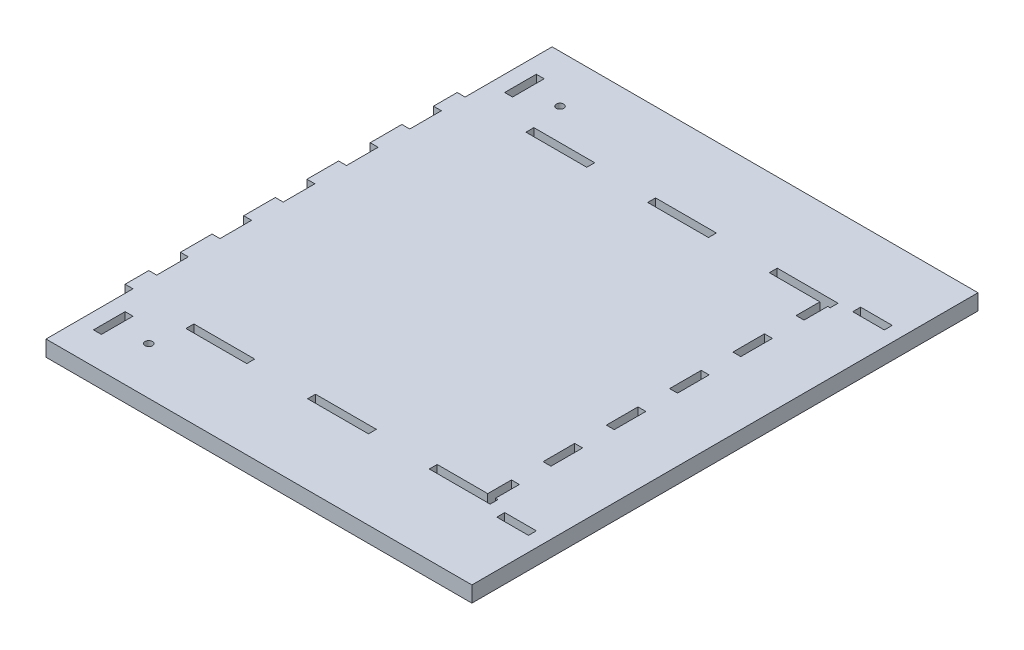
from build123d import *

# Parameters (mm, degrees)
SKETCH1_W           = 24.429357143
SKETCH1_H           = 3.175
SKETCH1_W_2         = 24.429357142
SKETCH1_W_3         = 3.175
SKETCH1_H_2         = 12.7
BOSS_EXTRUDE1_DEPTH = 6.35
SKETCH2_R           = 1.499997
SKETCH2_R_2         = 1.5
SKETCH2_W           = 12.7
SKETCH2_H           = 3.175
SKETCH2_W_2         = 3.175
SKETCH2_H_2         = 12.7
CUT_EXTRUDE1_DEPTH  = 7.35
SKETCH3_W           = 171.0055
SKETCH3_H           = 101.6
SKETCH3_H_2         = 44.45
CUT_EXTRUDE2_DEPTH  = 7.35


with BuildPart() as part:
    # Sketch1 → Boss-Extrude1 (new body)
    with BuildSketch(Plane(origin=(0, 0, 0), x_dir=(1, 0, 0), z_dir=(0, 1, 0))):
        Polygon((0, 174.625), (0, 95.25), (-3.175, 95.25), (-3.175, 85.725), (0, 85.725), (0, 73.025), (-3.175, 73.025), (-3.175, 60.325), (0, 60.325), (0, 47.625), (-3.175, 47.625), (-3.175, 34.925), (0, 34.925), (0, 22.225), (-3.175, 22.225), (-3.175, 9.525), (0, 9.525), (0, -3.175), (-3.175, -3.175), (-3.175, -15.875), (0, -15.875), (0, -28.575), (-3.175, -28.575), (-3.175, -38.1), (0, -38.1), (0, -174.625), (171.0055, -174.625), (171.0055, 174.625), align=None)
        with Locations((36.644035714, -39.6875)):
            Rectangle(SKETCH1_W, SKETCH1_H, mode=Mode.SUBTRACT)
        with Locations((85.50275, -39.6875)):
            Rectangle(SKETCH1_W_2, SKETCH1_H, mode=Mode.SUBTRACT)
        Polygon((122.146785714, -38.1), (142.4305, -38.1), (142.4305, -28.575), (145.6055, -28.575), (145.6055, -38.1), (146.576142857, -38.1), (146.576142857, -41.275), (122.146785714, -41.275), align=None, mode=Mode.SUBTRACT)
        with Locations((144.018, -9.525)):
            Rectangle(SKETCH1_W_3, SKETCH1_H_2, mode=Mode.SUBTRACT)
        with Locations((144.018, 15.875)):
            Rectangle(SKETCH1_W_3, SKETCH1_H_2, mode=Mode.SUBTRACT)
        with Locations((144.018, 41.275)):
            Rectangle(SKETCH1_W_3, SKETCH1_H_2, mode=Mode.SUBTRACT)
        with Locations((144.018, 66.675)):
            Rectangle(SKETCH1_W_3, SKETCH1_H_2, mode=Mode.SUBTRACT)
        Polygon((142.4305, 85.725), (142.4305, 95.25), (122.146785714, 95.25), (122.146785714, 98.425), (146.576142857, 98.425), (146.576142857, 95.25), (145.6055, 95.25), (145.6055, 85.725), align=None, mode=Mode.SUBTRACT)
        with Locations((85.50275, 96.8375)):
            Rectangle(SKETCH1_W_2, SKETCH1_H, mode=Mode.SUBTRACT)
        with Locations((36.644035714, 96.8375)):
            Rectangle(SKETCH1_W, SKETCH1_H, mode=Mode.SUBTRACT)
    extrude(amount=BOSS_EXTRUDE1_DEPTH)

    # Sketch2 → Cut-Extrude1 (cut, through all)
    with BuildSketch(Plane(origin=(0, 6.35, 0), x_dir=(1, 0, 0), z_dir=(0, 1, 0))):
        with Locations((9.525, -165.1)):
            Circle(SKETCH2_R)
        with Locations((9.525, 165.1)):
            Circle(SKETCH2_R)
        with Locations((22.225, -53.975)):
            Circle(SKETCH2_R_2)
        with Locations((22.225, 111.125)):
            Circle(SKETCH2_R_2)
        with Locations((158.790821429, -42.8625)):
            Rectangle(SKETCH2_W, SKETCH2_H)
        with Locations((158.790821429, 100.0125)):
            Rectangle(SKETCH2_W, SKETCH2_H)
        with Locations((7.9375, -53.975)):
            Rectangle(SKETCH2_W_2, SKETCH2_H_2)
        with Locations((7.9375, 111.125)):
            Rectangle(SKETCH2_W_2, SKETCH2_H_2)
    extrude(amount=-CUT_EXTRUDE1_DEPTH, mode=Mode.SUBTRACT)

    # Sketch3 → Cut-Extrude2 (cut, through all)
    with BuildSketch(Plane(origin=(0, 6.35, 0), x_dir=(1, 0, 0), z_dir=(0, 1, 0))):
        with Locations((85.50275, -123.825)):
            Rectangle(SKETCH3_W, SKETCH3_H)
        with Locations((85.50275, 152.4)):
            Rectangle(SKETCH3_W, SKETCH3_H_2)
    extrude(amount=-CUT_EXTRUDE2_DEPTH, mode=Mode.SUBTRACT)


solid = part.part
